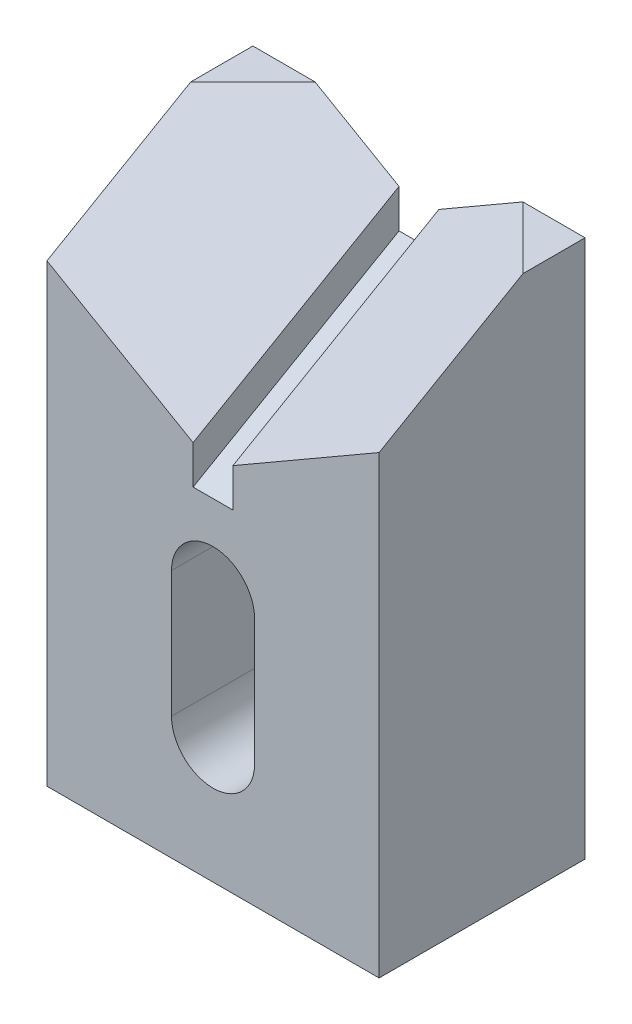
from build123d import *

# Parameters (mm, degrees)
SKETCH1_W           = 50.8
SKETCH1_H           = 82.296
BOSS_EXTRUDE1_DEPTH = 31.496
CUT_EXTRUDE1_DEPTH  = 37.523148695


with BuildPart() as part:
    # Sketch1 → Boss-Extrude1 (new body)
    with BuildSketch(Plane.XY):
        with Locations((0, 41.148)):
            Rectangle(SKETCH1_W, SKETCH1_H)
        with BuildLine():
            Line((6.35, 38.1), (6.35, 18.796))
            ThreePointArc((6.35, 18.796), (0, 12.446), (-6.35, 18.796))
            Line((-6.35, 18.796), (-6.35, 38.1))
            ThreePointArc((-6.35, 38.1), (0, 44.45), (6.35, 38.1))
        make_face(mode=Mode.SUBTRACT)
    extrude(amount=BOSS_EXTRUDE1_DEPTH)

    # Sketch2 → Cut-Extrude1 (cut, through all, along a direction that is not the sketch's normal)
    with BuildSketch(Plane.XY.offset(31.496)):
        Polygon((-25.4, 69.596), (-3.048, 56.691066783), (-3.048, 50.8), (3.048, 50.8), (3.048, 56.691066783), (25.4, 69.596), (25.4, 82.296), (-25.4, 82.296), align=None)
    extrude(amount=-CUT_EXTRUDE1_DEPTH, dir=(0, -0.5, 0.866025404), mode=Mode.SUBTRACT)


solid = part.part
